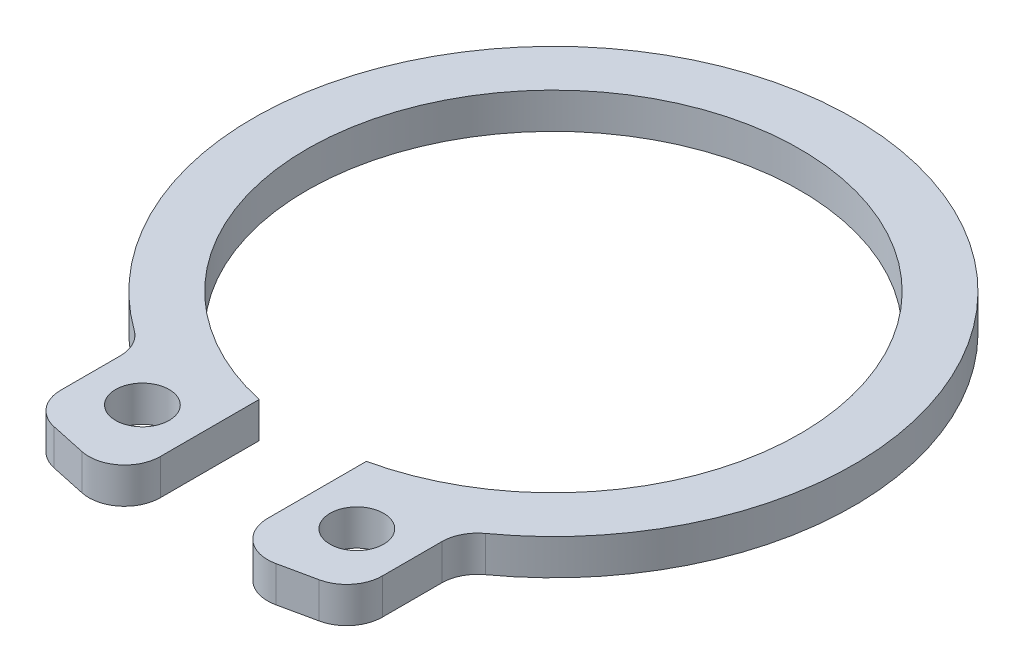
from build123d import *

# Parameters (mm, degrees)
EXTRUDE_1_DEPTH     = 1
SKETCH_2_R          = 0.75
CUT_EXTRUDE_1_DEPTH = 2
FILLET_1_R          = 1


with BuildPart() as part:
    # 草图1 → 凸台-拉伸1 (new body)
    with BuildSketch(Plane(origin=(0, 0, 0), x_dir=(1, 0, 0), z_dir=(0, 1, 0))):
        with BuildLine():
            Line((-4.5, -7.092954251), (-4.5, -10.092954251))
            Line((-4.5, -10.092954251), (-1.5, -10.734983296))
            Line((-1.5, -10.734983296), (-1.5, -6.734983296))
            ThreePointArc((-1.5, -6.734983296), (0, 6.9), (1.5, -6.734983296))
            Line((1.5, -6.734983296), (1.5, -10.734983296))
            Line((1.5, -10.734983296), (4.5, -10.092954251))
            Line((4.5, -10.092954251), (4.5, -7.092954251))
            ThreePointArc((4.5, -7.092954251), (0, 8.4), (-4.5, -7.092954251))
        make_face()
    extrude(amount=EXTRUDE_1_DEPTH)

    # 草图2 → 切除-拉伸1 (cut, through all)
    with BuildSketch(Plane(origin=(0, 1, 0), x_dir=(1, 0, 0), z_dir=(0, 1, 0))):
        with Locations((-3, -8.5)):
            Circle(SKETCH_2_R)
        with Locations((3, -8.5)):
            Circle(SKETCH_2_R)
    extrude(amount=-CUT_EXTRUDE_1_DEPTH, mode=Mode.SUBTRACT)

    # 圆角1
    fillet_1_edges = [part.edges().sort_by_distance(p)[0] for p in [
        (4.5, 0.5, 7.092954251),
        (4.5, 0.5, 10.092954251),
        (1.5, 0.5, 10.734983296),
        (-1.5, 0.5, 10.734983296),
        (-4.5, 0.5, 10.092954251),
        (-4.5, 0.5, 7.092954251),
    ]]
    fillet(fillet_1_edges, radius=FILLET_1_R)


solid = part.part
